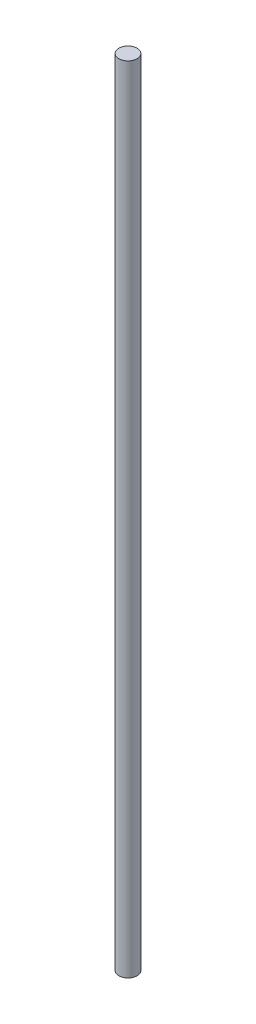
from build123d import *

# Parameters (mm, degrees)
SKETCH1_R           = 1.75
BOSS_EXTRUDE1_DEPTH = 152.4


with BuildPart() as part:
    # Sketch1 → Boss-Extrude1 (new body)
    with BuildSketch(Plane(origin=(0, 0, 0), x_dir=(1, 0, 0), z_dir=(0, 1, 0))):
        Circle(SKETCH1_R)
    extrude(amount=BOSS_EXTRUDE1_DEPTH)


solid = part.part
